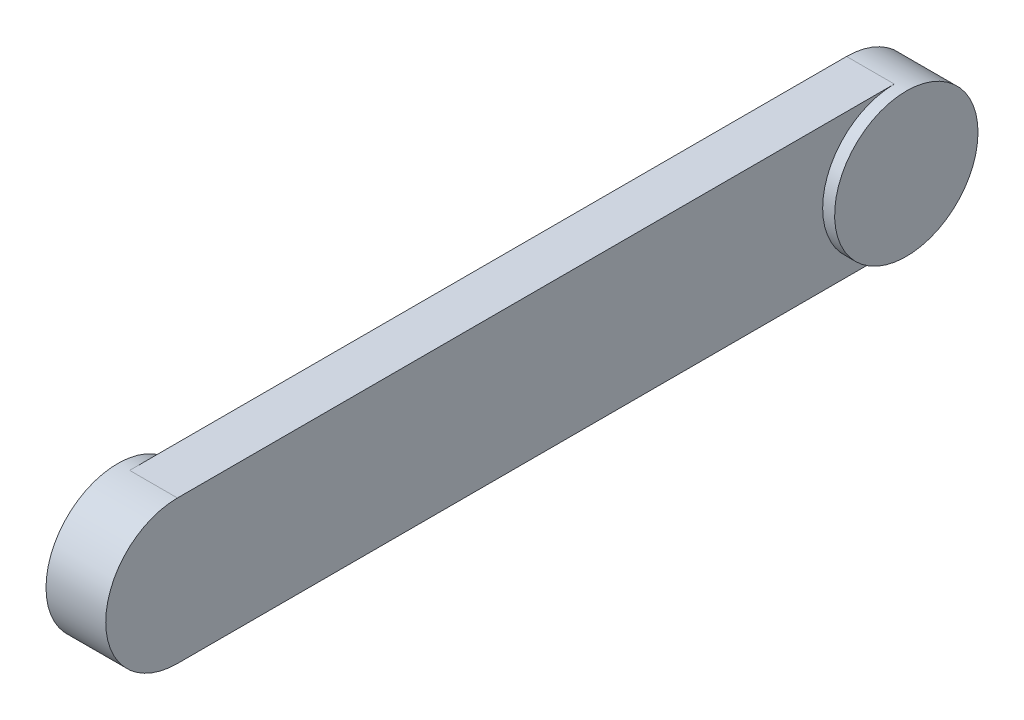
from build123d import *

# Parameters (mm, degrees)
EXTRUDE_1_DEPTH = 20
SKETCH_2_R      = 30
EXTRUDE_2_DEPTH = 5
SKETCH_3_R      = 30
EXTRUDE_3_DEPTH = 5


with BuildPart() as part:
    # 草图1 → 凸台-拉伸1 (new body)
    with BuildSketch(Plane(origin=(0, 0, 0), x_dir=(0, 0, -1), z_dir=(1, 0, 0))):
        with BuildLine():
            Line((0, 30), (300, 30))
            ThreePointArc((300, 30), (330, 0), (300, -30))
            Line((300, -30), (0, -30))
            ThreePointArc((0, -30), (-30, 0), (0, 30))
        make_face()
    extrude(amount=EXTRUDE_1_DEPTH)

    # 草图2 → 凸台-拉伸2 (add)
    with BuildSketch(Plane(origin=(20, 0, 0), x_dir=(0, 0, -1), z_dir=(1, 0, 0))):
        with Locations(Location((300, 0, 0), (0, 0, 90))):
            Circle(SKETCH_2_R)
    extrude(amount=EXTRUDE_2_DEPTH)

    # 草图3 → 凸台-拉伸3 (add)
    with BuildSketch(Plane.ZY):
        Circle(SKETCH_3_R)
    extrude(amount=EXTRUDE_3_DEPTH)


solid = part.part
